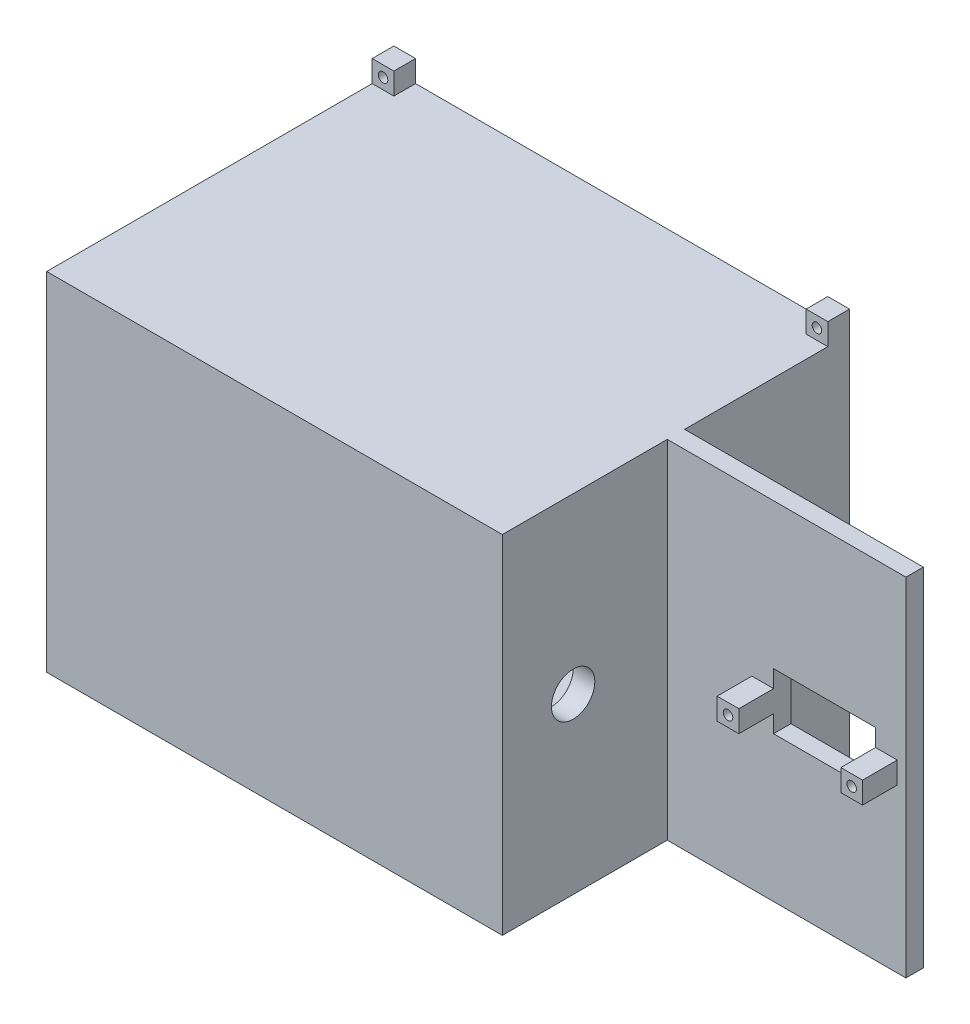
from build123d import *

# Parameters (mm, degrees)
SKETCH_1_W                = 160
SKETCH_1_H                = 80
EXTRUDE_1_DEPTH           = 80
SKETCH_10_W               = 21.5
SKETCH_10_H               = 15
CUT_EXTRUDE_6_DEPTH       = 10
SKETCH_11_W               = 55
SKETCH_11_H               = 80
CUT_EXTRUDE_7_DEPTH       = 38
SKETCH_12_W               = 55
SKETCH_12_H               = 80
CUT_EXTRUDE_8_DEPTH       = 38
SKETCH_14_W               = 95
SKETCH_14_H               = 70
CUT_EXTRUDE_9_DEPTH       = 75
SKETCH_15_W               = 102.8
SKETCH_15_H               = 77.8
SKETCH_15_W_2             = 97.2
SKETCH_15_H_2             = 72.2
CUT_EXTRUDE_10_DEPTH      = 10
SKETCH_16_W               = 5
SKETCH_16_H               = 5
SKETCH_16_R               = 1.1
EXTRUDE_2_DEPTH           = 5
SKETCH_17_R               = 5
CUT_EXTRUDE_12_DEPTH      = 9.2
SKETCH_18_W               = 23.5
SKETCH_18_H               = 13
CUT_EXTRUDE_13_DEPTH      = 9.2
SKETCH_19_W               = 5
SKETCH_19_H               = 5
SKETCH_19_R               = 1.1
EXTRUDE_3_DEPTH           = 12
SKETCH_20_R               = 1.1
CUT_EXTRUDE_14_DEPTH      = 5
CUT_EXTRUDE_14_DEPTH_BACK = 5


with BuildPart() as part:
    # 草圖1 → 填料-伸長1 (new body)
    with BuildSketch(Plane.XY):
        with Locations((4.491097826, 5.58988764)):
            Rectangle(SKETCH_1_W, SKETCH_1_H)
    extrude(amount=EXTRUDE_1_DEPTH)

    # 草圖10 → 除料-伸長6 (cut)
    with BuildSketch(Plane(origin=(0, -34.41011236, 0), x_dir=(-1, 0, 0), z_dir=(0, -1, 0))):
        with Locations((24.758902174, -22.5)):
            Rectangle(SKETCH_10_W, SKETCH_10_H)
    extrude(amount=-CUT_EXTRUDE_6_DEPTH, mode=Mode.SUBTRACT)

    # 草圖11 → 除料-伸長7 (cut)
    with BuildSketch(Plane(origin=(0, 0, 0), x_dir=(-1, 0, 0), z_dir=(0, 0, -1))):
        with Locations((-56.991097826, 5.58988764)):
            Rectangle(SKETCH_11_W, SKETCH_11_H)
    extrude(amount=-CUT_EXTRUDE_7_DEPTH, mode=Mode.SUBTRACT)

    # 草圖12 → 除料-伸長8 (cut)
    with BuildSketch(Plane.XY.offset(80)):
        with Locations((56.991097826, 5.58988764)):
            Rectangle(SKETCH_12_W, SKETCH_12_H)
    extrude(amount=-CUT_EXTRUDE_8_DEPTH, mode=Mode.SUBTRACT)

    # 草圖14 → 除料-伸長9 (cut)
    with BuildSketch(Plane(origin=(0, 0, 0), x_dir=(-1, 0, 0), z_dir=(0, 0, -1))):
        with Locations((23.008902174, 5.58988764)):
            Rectangle(SKETCH_14_W, SKETCH_14_H)
    extrude(amount=-CUT_EXTRUDE_9_DEPTH, mode=Mode.SUBTRACT)

    # 草圖15 → 除料-伸長10 (cut)
    with BuildSketch(Plane(origin=(0, 0, 0), x_dir=(-1, 0, 0), z_dir=(0, 0, -1))):
        with Locations((23.008902174, 5.58988764)):
            Rectangle(SKETCH_15_W, SKETCH_15_H)
        with Locations((23.008902174, 5.58988764)):
            Rectangle(SKETCH_15_W_2, SKETCH_15_H_2, mode=Mode.SUBTRACT)
    extrude(amount=-CUT_EXTRUDE_10_DEPTH, mode=Mode.SUBTRACT)

    # 草圖16 → 填料-伸長2 (add)
    with BuildSketch(Plane(origin=(0, 0, 0), x_dir=(-1, 0, 0), z_dir=(0, 0, -1))):
        with Locations((-26.991097826, 48.08988764)):
            Rectangle(SKETCH_16_W, SKETCH_16_H)
        with Locations((-26.991097826, 48.08988764)):
            Circle(SKETCH_16_R, mode=Mode.SUBTRACT)
        with Locations((73.008902174, 48.08988764)):
            Rectangle(SKETCH_16_W, SKETCH_16_H)
        with Locations((73.008902174, 48.08988764)):
            Circle(SKETCH_16_R, mode=Mode.SUBTRACT)
        with Locations((73.008902174, -36.91011236)):
            Rectangle(SKETCH_16_W, SKETCH_16_H)
        with Locations((73.008902174, -36.91011236)):
            Circle(SKETCH_16_R, mode=Mode.SUBTRACT)
        with Locations((-26.991097826, -36.91011236)):
            Rectangle(SKETCH_16_W, SKETCH_16_H)
        with Locations((-26.991097826, -36.91011236)):
            Circle(SKETCH_16_R, mode=Mode.SUBTRACT)
    extrude(amount=-EXTRUDE_2_DEPTH)

    # 草圖17 → 除料-伸長12 (cut)
    with BuildSketch(Plane(origin=(29.491097826, 0, 0), x_dir=(0, 0, -1), z_dir=(1, 0, 0))):
        with Locations((-63.691723703, 5.58988764)):
            Circle(SKETCH_17_R)
        with Locations((-16.308276297, 5.58988764)):
            Circle(SKETCH_17_R)
    extrude(amount=-CUT_EXTRUDE_12_DEPTH, mode=Mode.SUBTRACT)

    # 草圖18 → 除料-伸長13 (cut)
    with BuildSketch(Plane(origin=(0, 0, 38), x_dir=(-1, 0, 0), z_dir=(0, 0, -1))):
        with Locations((-65.741097826, 5.58988764)):
            Rectangle(SKETCH_18_W, SKETCH_18_H)
    extrude(amount=-CUT_EXTRUDE_13_DEPTH, mode=Mode.SUBTRACT)

    # 草圖19 → 填料-伸長3 (add)
    with BuildSketch(Plane(origin=(0, 0, 38), x_dir=(-1, 0, 0), z_dir=(0, 0, -1))):
        with Locations((-79.991097826, 5.58988764)):
            Rectangle(SKETCH_19_W, SKETCH_19_H)
        with Locations((-79.991097826, 5.58988764)):
            Circle(SKETCH_19_R, mode=Mode.SUBTRACT)
        with Locations((-51.491097826, 5.58988764)):
            Rectangle(SKETCH_19_W, SKETCH_19_H)
        with Locations((-51.491097826, 5.58988764)):
            Circle(SKETCH_19_R, mode=Mode.SUBTRACT)
    extrude(amount=-EXTRUDE_3_DEPTH)

    # 草圖20 → 除料-伸長14 (cut, two sides)
    with BuildSketch(Plane(origin=(0, 0, 38), x_dir=(-1, 0, 0), z_dir=(0, 0, -1))) as cut_extrude_14_sk:
        with Locations((-79.991097826, 5.58988764)):
            Circle(SKETCH_20_R)
        with Locations((-51.491097826, 5.58988764)):
            Circle(SKETCH_20_R)
    extrude(amount=CUT_EXTRUDE_14_DEPTH, mode=Mode.SUBTRACT)
    extrude(cut_extrude_14_sk.sketch, amount=-CUT_EXTRUDE_14_DEPTH_BACK, mode=Mode.SUBTRACT)


solid = part.part
